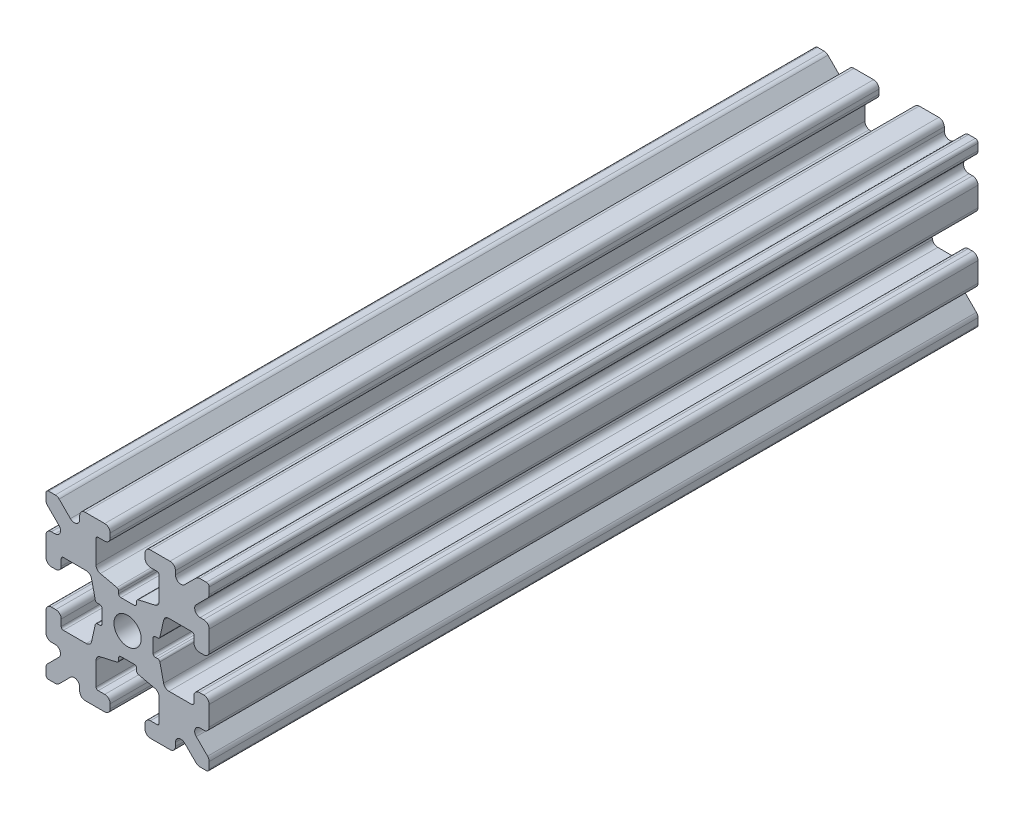
from build123d import *

# Parameters (mm, degrees)
SKETCH1_W           = 15
SKETCH1_H           = 15
SKETCH1_R           = 1.25
BOSS_EXTRUDE1_DEPTH = 35.33902
FILLET1_R           = 0.25
CUT_EXTRUDE1_DEPTH  = 71.67804
CUT_EXTRUDE3_DEPTH  = 71.67804
FILLET3_R           = 0.5
FILLET4_R           = 0.5
FILLET5_R           = 3
FILLET6_R           = 0.2
CUT_EXTRUDE4_DEPTH  = 71.67804
FILLET8_R           = 0.5
SKETCH6_W           = 5.1529354
SKETCH6_H           = 1.651
SKETCH6_W_2         = 1.651
SKETCH6_H_2         = 5.1529354
CUT_EXTRUDE5_DEPTH  = 71.67804
FILLET10_R          = 0.2


with BuildPart() as part:
    # Sketch1 → Boss-Extrude1 (new body, symmetric)
    with BuildSketch(Plane.XY):
        Rectangle(SKETCH1_W, SKETCH1_H)
        Circle(SKETCH1_R, mode=Mode.SUBTRACT)
    extrude(amount=BOSS_EXTRUDE1_DEPTH, both=True)

    # Fillet1
    fillet1_edges = [part.edges().sort_by_distance(p)[0] for p in [
        (7.5, -7.5, 0),
        (-7.5, -7.5, 0),
        (-7.5, 7.5, 0),
        (7.5, 7.5, 0),
    ]]
    fillet(fillet1_edges, radius=FILLET1_R)

    # Sketch2 → Cut-Extrude1 (cut, through all)
    with BuildSketch(Plane.XY.offset(35.33902)):
        Polygon((-7.5, 1.6), (-6.1, 1.6), (-6.1, 2.9), (-3.4, 2.9), (-3.4, -2.9), (-6.1, -2.9), (-6.1, -1.6), (-7.5, -1.6), align=None)
        Polygon((2.9, 6.1), (1.6, 6.1), (1.6, 7.5), (-1.6, 7.5), (-1.6, 6.1), (-2.9, 6.1), (-2.9, 3.4), (2.9, 3.4), align=None)
        Polygon((-1.6, -7.5), (-1.6, -6.1), (-2.9, -6.1), (-2.9, -3.4), (2.9, -3.4), (2.9, -6.1), (1.6, -6.1), (1.6, -7.5), align=None)
        Polygon((6.1, -2.9), (6.1, -1.6), (7.5, -1.6), (7.5, 1.6), (6.1, 1.6), (6.1, 2.9), (3.4, 2.9), (3.4, -2.9), align=None)
    extrude(amount=-CUT_EXTRUDE1_DEPTH, mode=Mode.SUBTRACT)

    # Sketch4 → Cut-Extrude3 (cut, through all)
    with BuildSketch(Plane.XY.offset(35.33902)):
        Polygon((-3.4, 2.9), (-2.75, 0), (-3.4, -2.9), align=None)
        Polygon((-2.9, 3.4), (0, 2.75), (2.9, 3.4), align=None)
        Polygon((3.4, 2.9), (2.75, 0), (3.4, -2.9), align=None)
        Polygon((-2.9, -3.4), (0, -2.75), (2.9, -3.4), align=None)
    extrude(amount=-CUT_EXTRUDE3_DEPTH, mode=Mode.SUBTRACT)

    # Fillet3
    fillet3_edges = [part.edges().sort_by_distance(p)[0] for p in [
        (1.6, -7.5, 0),
        (-1.6, -7.5, 0),
        (-1.6, -6.1, 0),
        (1.6, -6.1, 0),
        (6.1, 1.6, 0),
        (7.5, 1.6, 0),
        (7.5, -1.6, 0),
        (6.1, -1.6, 0),
        (-7.5, -1.6, 0),
        (-7.5, 1.6, 0),
        (-6.1, 1.6, 0),
        (-6.1, -1.6, 0),
        (-1.6, 6.1, 0),
        (-1.6, 7.5, 0),
        (1.6, 7.5, 0),
        (1.6, 6.1, 0),
    ]]
    fillet(fillet3_edges, radius=FILLET3_R)

    # Fillet4
    fillet4_edges = [part.edges().sort_by_distance(p)[0] for p in [
        (-2.9, -3.4, 0),
        (2.9, -3.4, 0),
        (3.4, -2.9, 0),
        (3.4, 2.9, 0),
        (-3.4, 2.9, 0),
        (-3.4, -2.9, 0),
        (2.9, 3.4, 0),
        (-2.9, 3.4, 0),
    ]]
    fillet(fillet4_edges, radius=FILLET4_R)

    # Fillet5
    fillet5_edges = [part.edges().sort_by_distance(p)[0] for p in [
        (-2.75, 0, 0),
        (0, 2.75, 0),
        (2.75, 0, 0),
        (0, -2.75, 0),
    ]]
    fillet(fillet5_edges, radius=FILLET5_R)

    # Fillet6
    fillet6_edges = [part.edges().sort_by_distance(p)[0] for p in [
        (-2.9, -6.1, 0),
        (2.9, -6.1, 0),
        (6.1, -2.9, 0),
        (6.1, 2.9, 0),
        (-6.1, 2.9, 0),
        (-6.1, -2.9, 0),
        (2.9, 6.1, 0),
        (-2.9, 6.1, 0),
    ]]
    fillet(fillet6_edges, radius=FILLET6_R)

    # Sketch5 → Cut-Extrude4 (cut, through all)
    with BuildSketch(Plane.XY.offset(35.33902)):
        Polygon((-7.5, 6.439339828), (-5.460660172, 4.4), (-7.5, 4.4), align=None)
        Polygon((-6.439339828, 7.5), (-4.4, 5.460660172), (-4.4, 7.5), align=None)
        Polygon((4.4, 7.5), (6.439339828, 7.5), (4.4, 5.460660172), align=None)
        Polygon((7.5, 6.439339828), (7.5, 4.4), (5.460660172, 4.4), align=None)
        Polygon((7.5, -6.439339828), (5.460660172, -4.4), (7.5, -4.4), align=None)
        Polygon((6.439339828, -7.5), (4.4, -5.460660172), (4.4, -7.5), align=None)
        Polygon((-4.4, -7.5), (-6.439339828, -7.5), (-4.4, -5.460660172), align=None)
        Polygon((-7.5, -6.439339828), (-7.5, -4.4), (-5.460660172, -4.4), align=None)
    extrude(amount=-CUT_EXTRUDE4_DEPTH, mode=Mode.SUBTRACT)

    # Fillet8
    fillet8_edges = [part.edges().sort_by_distance(p)[0] for p in [
        (-7.5, 4.4, 0),
        (-7.5, 6.439339828, 0),
        (-5.460660172, 4.4, 0),
        (7.5, -4.4, 0),
        (7.5, -6.439339828, 0),
        (5.460660172, -4.4, 0),
        (5.460660172, 4.4, 0),
        (7.5, 6.439339828, 0),
        (7.5, 4.4, 0),
        (-4.4, 7.5, 0),
        (-4.4, 5.460660172, 0),
        (-6.439339828, 7.5, 0),
        (-5.460660172, -4.4, 0),
        (-7.5, -6.439339828, 0),
        (-7.5, -4.4, 0),
        (4.4, 5.460660172, 0),
        (4.4, 7.5, 0),
        (6.439339828, 7.5, 0),
        (6.439339828, -7.5, 0),
        (4.4, -7.5, 0),
        (4.4, -5.460660172, 0),
        (-6.439339828, -7.5, 0),
        (-4.4, -5.460660172, 0),
        (-4.4, -7.5, 0),
    ]]
    fillet(fillet8_edges, radius=FILLET8_R)

    # Sketch6 → Cut-Extrude5 (cut, through all)
    with BuildSketch(Plane.XY.offset(35.33902)):
        with Locations((4.9235323, 0)):
            Rectangle(SKETCH6_W, SKETCH6_H)
        with Locations((0, -4.9235323)):
            Rectangle(SKETCH6_W_2, SKETCH6_H_2)
        with Locations((-4.9235323, 0)):
            Rectangle(SKETCH6_W, SKETCH6_H)
        with Locations((0, 4.9235323)):
            Rectangle(SKETCH6_W_2, SKETCH6_H_2)
    extrude(amount=-CUT_EXTRUDE5_DEPTH, mode=Mode.SUBTRACT)

    # Fillet10
    fillet10_edges = [part.edges().sort_by_distance(p)[0] for p in [
        (0.8255, -2.935025862, 0),
        (-0.8255, -2.935025862, 0),
        (0.8255, -2.3470646, 0),
        (-0.8255, -2.3470646, 0),
        (2.935025862, 0.8255, 0),
        (2.935025862, -0.8255, 0),
        (2.3470646, 0.8255, 0),
        (2.3470646, -0.8255, 0),
        (-2.935025862, -0.8255, 0),
        (-2.935025862, 0.8255, 0),
        (-2.3470646, -0.8255, 0),
        (-2.3470646, 0.8255, 0),
        (-0.8255, 2.935025862, 0),
        (0.8255, 2.935025862, 0),
        (-0.8255, 2.3470646, 0),
        (0.8255, 2.3470646, 0),
    ]]
    fillet(fillet10_edges, radius=FILLET10_R)


solid = part.part
